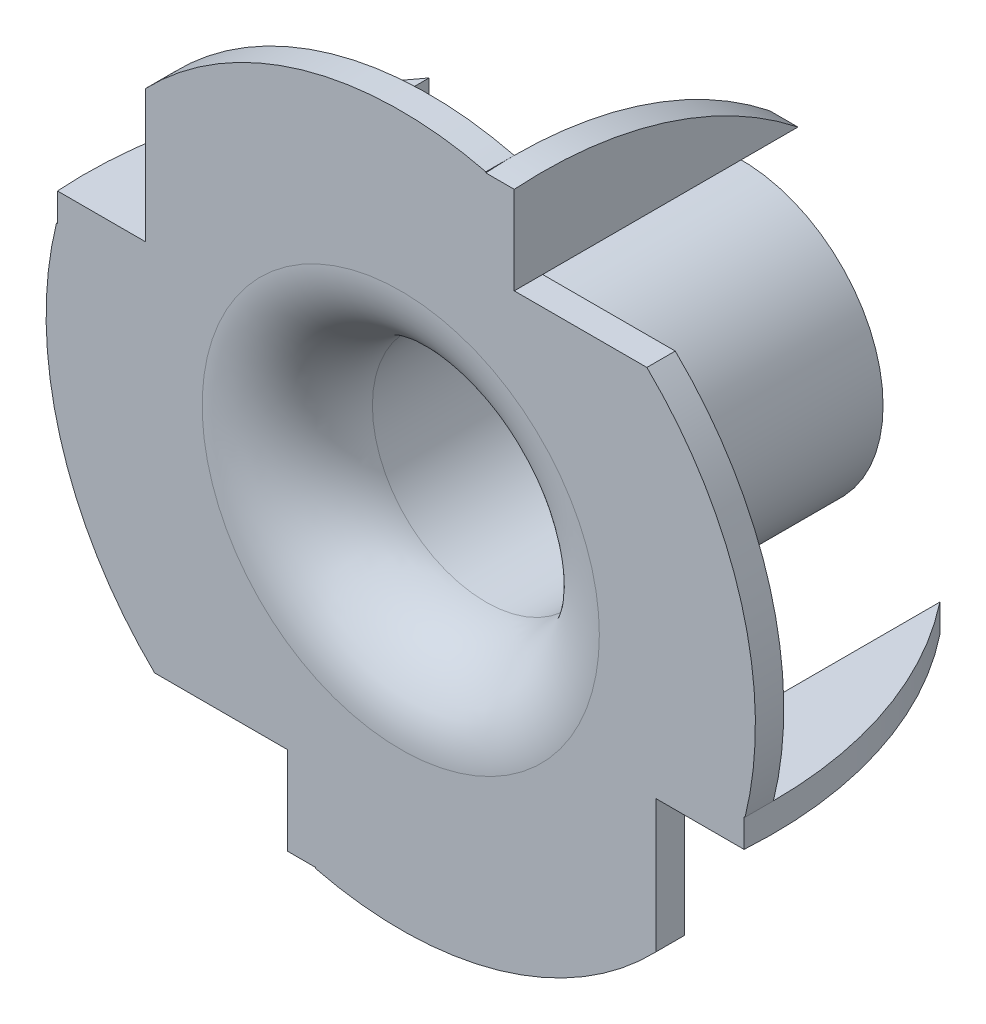
from build123d import *

# Parameters (mm, degrees)
CUT_EXTRUDE1_DEPTH      = 12
CUT_EXTRUDE1_DEPTH_BACK = 2
BOSS_EXTRUDE1_DEPTH     = 1
CIRPATTERN4_COUNT       = 4


with BuildPart() as part:
    # Sketch1 → Revolve1 (revolve)
    with BuildSketch(Plane(origin=(0, 0, 0), x_dir=(1, 0, 0), z_dir=(0, 1, 0))):
        with BuildLine():
            Line((8.5, 7.032838072), (8.5, 2.5))
            ThreePointArc((8.5, 2.5), (7.621320344, 0.378679656), (5.5, -0.5))
            Line((5.5, -0.5), (0, -0.5))
            Line((0, -0.5), (0, 0.5))
            Line((0, 0.5), (5.5, 0.5))
            ThreePointArc((5.5, 0.5), (6.914213562, 1.085786438), (7.5, 2.5))
            Line((7.5, 2.5), (7.5, 11.5))
            Line((7.5, 11.5), (8.5, 11.5))
            Line((8.5, 11.5), (8.5, 7.032838072))
        make_face()
    revolve(axis=Axis((12.5, 0, 0), (0, 0, -1)))

    # Sketch2 → Cut-Extrude1 (cut, two sides)
    with BuildSketch(Plane(origin=(0, 0, -0.5), x_dir=(-1, 0, 0), z_dir=(0, 0, -1))) as cut_extrude1_sk:
        with BuildLine():
            Line((-3.5, 8.674675786), (-3.5, 3))
            Line((-3.5, 3), (-0.3653389, 3))
            ThreePointArc((-0.3653389, 3), (-1.558383974, 6.044091225), (-3.5, 8.674675786))
        make_face()
        with BuildLine():
            Line((-3.825324214, -9), (-9.5, -9))
            Line((-9.5, -9), (-9.5, -12.1346611))
            ThreePointArc((-9.5, -12.1346611), (-6.455908775, -10.941616026), (-3.825324214, -9))
        make_face()
        with BuildLine():
            Line((-21.5, -8.674675786), (-21.5, -3))
            Line((-21.5, -3), (-24.6346611, -3))
            ThreePointArc((-24.6346611, -3), (-23.441616026, -6.044091225), (-21.5, -8.674675786))
        make_face()
        with BuildLine():
            Line((-21.174675786, 9), (-15.5, 9))
            Line((-15.5, 9), (-15.5, 12.1346611))
            ThreePointArc((-15.5, 12.1346611), (-18.544091225, 10.941616026), (-21.174675786, 9))
        make_face()
    extrude(amount=CUT_EXTRUDE1_DEPTH, mode=Mode.SUBTRACT)
    extrude(cut_extrude1_sk.sketch, amount=-CUT_EXTRUDE1_DEPTH_BACK, mode=Mode.SUBTRACT)

    # Sketch3 → Boss-Extrude1 (add)
    with BuildSketch(Plane(origin=(0, 3, 0), x_dir=(1, 0, 0), z_dir=(0, 1, 0))):
        with BuildLine():
            Line((0.3653389, 0.5), (3.5, 0.5))
            Line((3.5, 0.5), (3.5, 9.5))
            ThreePointArc((3.5, 9.5), (1.171429987, 5.265136415), (0.3653389, 0.5))
        make_face()
        with BuildLine():
            Line((3.5, -0.5), (3.5, 0.5))
            Line((3.5, 0.5), (0.3653389, 0.5))
            ThreePointArc((0.3653389, 0.5), (0.373979974, -0.000298405), (0.399892887, -0.5))
            Line((0.399892887, -0.5), (3.5, -0.5))
        make_face()
    boss_extrude1 = extrude(amount=BOSS_EXTRUDE1_DEPTH)

    # CirPattern4: Boss-Extrude1 ×4 about axis
    cirpattern4_axis = Axis((12.5, 0, 0), (0, 0, 1))
    for i in range(1, CIRPATTERN4_COUNT):
        add(boss_extrude1.rotate(cirpattern4_axis, i * 360 / CIRPATTERN4_COUNT))


solid = part.part
